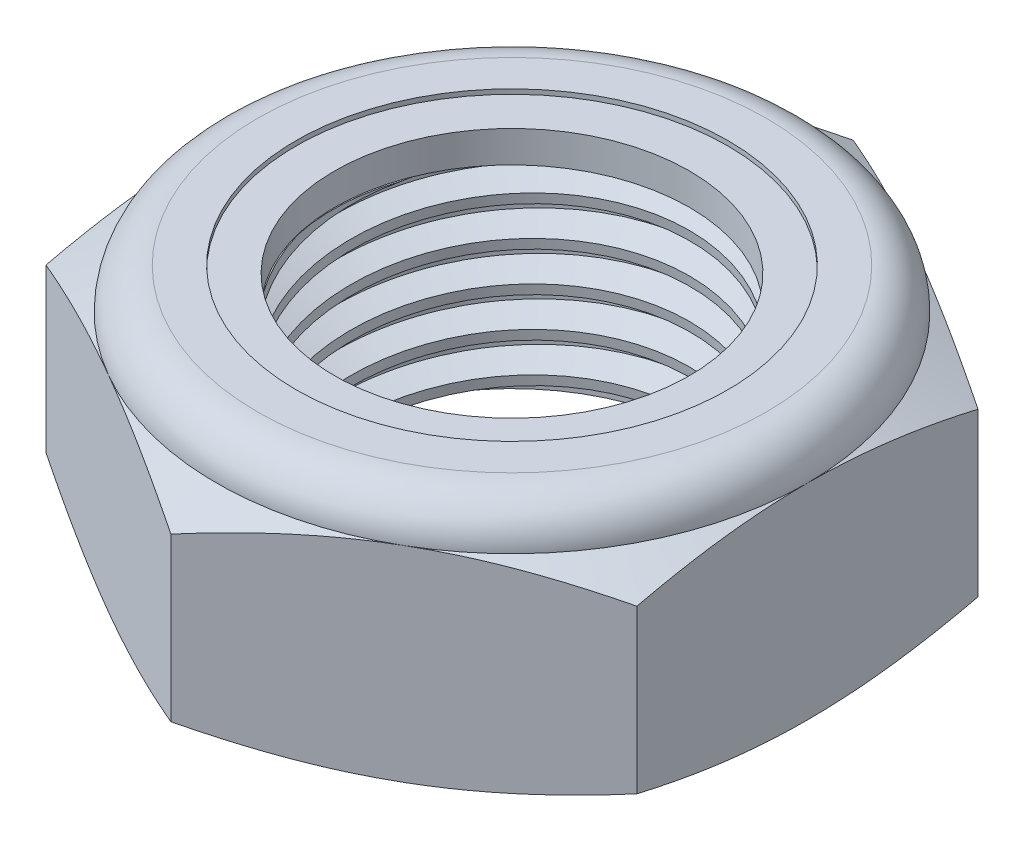
from build123d import *

# Parameters (mm, degrees)
EXTRUDE1_DEPTH      = 7.9375
SKETCH2_W           = 6.35
SKETCH2_H           = 7.9375
LPATTERN1_COUNT     = 6
LPATTERN1_PITCH     = 1.27
LPATTERN1_COL_COUNT = 2
LPATTERN1_COL_PITCH = 1.27


with BuildPart() as part:
    # Sketch1 → Extrude1 (new body)
    with BuildSketch(Plane(origin=(0, 0, 0), x_dir=(1, 0, 0), z_dir=(0, 1, 0))):
        Polygon((0, 10.998522628), (-9.525, 5.499261314), (-9.525, -5.499261314), (0, -10.998522628), (9.525, -5.499261314), (9.525, 5.499261314), align=None)
    extrude(amount=EXTRUDE1_DEPTH)

    # Sketch4 → Cut-Revolve2 (revolve, cut)
    with BuildSketch(Plane(origin=(0, 0, 0), x_dir=(0, 0, -1), z_dir=(1, 0, 0))):
        Polygon((0, 7.9375), (6.35, 7.9375), (5.721290563, 7.644327975), (5.721290563, 0.293172025), (6.35, 0), (0, 0), align=None)
    revolve(axis=Axis((0, 7.9375, 0), (0, 1, 0)), mode=Mode.SUBTRACT)


with BuildPart() as body_2:
    # Sketch2 → Revolve1 (revolve)
    with BuildSketch(Plane(origin=(0, 0, 0), x_dir=(0, 0, -1), z_dir=(1, 0, 0))):
        with Locations((3.175, 3.96875)):
            Rectangle(SKETCH2_W, SKETCH2_H)
    revolve(axis=Axis((0, -6.35, 0), (0, 1, 0)))

    # Sketch3 → Cut-Revolve1 (revolve, cut)
    with BuildSketch(Plane(origin=(0, 0, 0), x_dir=(0, 0, -1), z_dir=(1, 0, 0))):
        Polygon((6.365796215, 7.779537846), (6.476369723, 6.673802768), (5.752882994, 7.000308534), (5.721290563, 7.316232842), align=None)
    cut_revolve1 = revolve(axis=Axis((0, 7.9375, 0.135293799), (0, -0.99503719, -0.099503719)), mode=Mode.SUBTRACT)

    # LPattern1: Cut-Revolve1 ×6
    with Locations(*[(0, -i * LPATTERN1_PITCH, 0) for i in range(1, LPATTERN1_COUNT)]):
        add(cut_revolve1, mode=Mode.SUBTRACT)

    # LPattern1 col: Cut-Revolve1 ×2
    with Locations(*[(0, i * LPATTERN1_COL_PITCH, 0) for i in range(1, LPATTERN1_COL_COUNT)]):
        add(cut_revolve1, mode=Mode.SUBTRACT)


with BuildPart() as part_1:
    add(part.part)

    # Combine1: cut body 2
    add(body_2.part, mode=Mode.SUBTRACT)

    # Sketch5 → Cut-Revolve3 (revolve, cut)
    with BuildSketch(Plane(origin=(0, 0, 0), x_dir=(0, 0, -1), z_dir=(1, 0, 0))):
        with BuildLine():
            Line((0, 0), (9.525, 0))
            Line((9.525, 0), (10.998522628, 0.687114886))
            Line((10.998522628, 0.687114886), (10.998522628, 5.927468447))
            Line((10.998522628, 5.927468447), (9.525, 6.614583333))
            ThreePointArc((9.525, 6.614583333), (9.137526679, 7.550026679), (8.202083333, 7.9375))
            Line((8.202083333, 7.9375), (8.202083333, 9.2075))
            Line((8.202083333, 9.2075), (12.268522628, 9.2075))
            Line((12.268522628, 9.2075), (12.268522628, -1.27))
            Line((12.268522628, -1.27), (0, -1.27))
            Line((0, -1.27), (0, 0))
        make_face()
    revolve(axis=Axis((0, 0, 0), (0, 1, 0)), mode=Mode.SUBTRACT)

    # Sketch6 → Cut-Revolve4 (revolve, cut)
    with BuildSketch(Plane(origin=(0, 0, 0), x_dir=(0, 0, -1), z_dir=(1, 0, 0))):
        with BuildLine():
            Line((0, 6.614583333), (9.3726, 6.614583333))
            ThreePointArc((9.3726, 6.614583333), (9.029763606, 7.442263606), (8.202083333, 7.7851))
            Line((8.202083333, 7.7851), (6.961686948, 7.7851))
            Line((6.961686948, 7.7851), (6.961686948, 9.2075))
            Line((6.961686948, 9.2075), (0, 9.2075))
            Line((0, 9.2075), (0, 6.614583333))
        make_face()
    revolve(axis=Axis((0, 9.2075, 0), (0, 1, 0)), mode=Mode.SUBTRACT)


with BuildPart() as body_2_2:
    # Sketch7 → Revolve2 (revolve)
    with BuildSketch(Plane(origin=(0, 0, 0), x_dir=(0, 0, -1), z_dir=(1, 0, 0))):
        with BuildLine():
            Line((5.721290563, 6.690783333), (9.293743778, 6.690783333))
            ThreePointArc((9.293743778, 6.690783333), (8.948455237, 7.4148695), (8.202083333, 7.7089))
            Line((8.202083333, 7.7089), (5.721290563, 7.7089))
            Line((5.721290563, 7.7089), (5.721290563, 6.690783333))
        make_face()
    revolve(axis=Axis((0, 6.690783333, 0), (0, 1, 0)))


solid = Compound([part_1.part, body_2_2.part])
